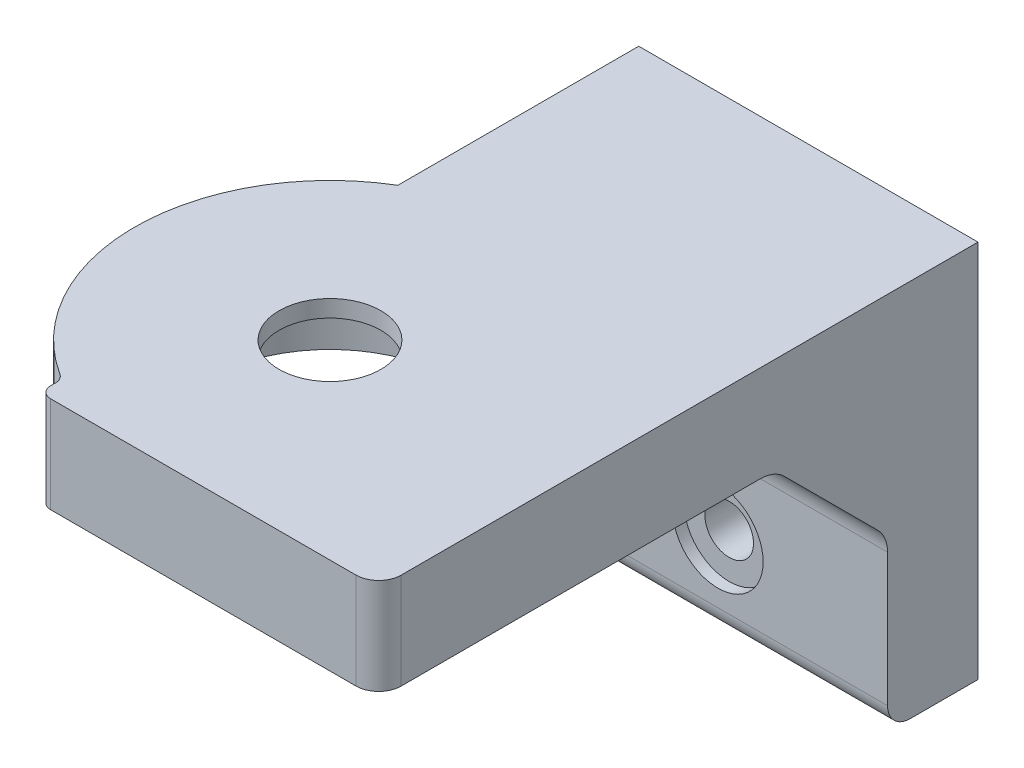
from build123d import *

# Parameters (mm, degrees)
CROQUIS3_R              = 11
CROQUIS3_R_2            = 4.5
SALIENTE_EXTRUIR2_DEPTH = 1.5
SALIENTE_EXTRUIR3_START = -1.5
CROQUIS3_3_R            = 11
SALIENTE_EXTRUIR3_DEPTH = 7
CROQUIS4_W              = 30
CROQUIS4_H              = 25
SALIENTE_EXTRUIR4_DEPTH = 8
CHAFL_N1_SIZE           = 10
CROQUIS5_R              = 2.15
CORTAR_EXTRUIR1_DEPTH   = 9
REDONDEO1_R             = 1
REDONDEO2_R             = 2
REDONDEO3_R             = 3
REDONDEO4_R             = 2
CROQUIS5_3_R            = 4
CROQUIS5_3_R_2          = 2.15
CORTAR_EXTRUIR2_DEPTH   = 1


with BuildPart() as part:
    # Croquis3 → Saliente-Extruir2 (new body)
    with BuildSketch(Plane(origin=(0, -625, 0), x_dir=(1, 0, 0), z_dir=(0, 1, 0))):
        with BuildLine():
            ThreePointArc((-40.300000436, -51), (-48.73713438, -36.15), (-40.300000436, -21.3))
            Line((-40.300000436, -21.3), (-40.300000436, 0))
            Line((-40.300000436, 0), (-10.300000436, 0))
            Line((-10.300000436, 0), (-10.300000436, -53))
            Line((-10.300000436, -53), (-40.300000436, -53))
            Line((-40.300000436, -53), (-40.300000436, -51))
        make_face()
        with Locations((-31.450000436, -36.15)):
            Circle(CROQUIS3_R, mode=Mode.SUBTRACT)
        with Locations((-31.450000436, -36.15)):
            Circle(CROQUIS3_R)
        with Locations((-31.450000436, -36.15)):
            Circle(CROQUIS3_R_2, mode=Mode.SUBTRACT)
    extrude(amount=-SALIENTE_EXTRUIR2_DEPTH)

    # Croquis3_3 → Saliente-Extruir3 (add)
    with BuildSketch(Plane(origin=(0, -625, 0), x_dir=(1, 0, 0), z_dir=(0, 1, 0)).offset(SALIENTE_EXTRUIR3_START)):
        with BuildLine():
            ThreePointArc((-40.300000436, -51), (-48.73713438, -36.15), (-40.300000436, -21.3))
            Line((-40.300000436, -21.3), (-40.300000436, 0))
            Line((-40.300000436, 0), (-10.300000436, 0))
            Line((-10.300000436, 0), (-10.300000436, -53))
            Line((-10.300000436, -53), (-40.300000436, -53))
            Line((-40.300000436, -53), (-40.300000436, -51))
        make_face()
        with Locations((-31.450000436, -36.15)):
            Circle(CROQUIS3_3_R, mode=Mode.SUBTRACT)
    extrude(amount=-SALIENTE_EXTRUIR3_DEPTH)

    # Croquis4 → Saliente-Extruir4 (add)
    with BuildSketch(Plane(origin=(0, 0, 0), x_dir=(-1, 0, 0), z_dir=(0, 0, -1))):
        with Locations((25.300000436, -646)):
            Rectangle(CROQUIS4_W, CROQUIS4_H)
    extrude(amount=-SALIENTE_EXTRUIR4_DEPTH)

    # Chaflán1
    chafl_n1_edges = [part.edges().sort_by_distance(p)[0] for p in [
        (-25.300000436, -633.5, 8),
    ]]
    chamfer(chafl_n1_edges, length=CHAFL_N1_SIZE)

    # Croquis5 → Cortar-Extruir1 (cut, through all)
    with BuildSketch(Plane.XY.offset(8)):
        with Locations((-25.300000436, -651)):
            Circle(CROQUIS5_R)
    extrude(amount=-CORTAR_EXTRUIR1_DEPTH, mode=Mode.SUBTRACT)

    # Redondeo1
    redondeo1_edges = [part.edges().sort_by_distance(p)[0] for p in [
        (-40.300000436, -629.25, 53),
        (-40.300000436, -629.25, 51),
    ]]
    fillet(redondeo1_edges, radius=REDONDEO1_R)

    # Redondeo2
    redondeo2_edges = [part.edges().sort_by_distance(p)[0] for p in [
        (-10.300000436, -629.25, 53),
    ]]
    fillet(redondeo2_edges, radius=REDONDEO2_R)

    # Redondeo3
    redondeo3_edges = [part.edges().sort_by_distance(p)[0] for p in [
        (-25.300000436, -633.5, 18),
        (-25.300000436, -643.5, 8),
    ]]
    fillet(redondeo3_edges, radius=REDONDEO3_R)

    # Redondeo4
    redondeo4_edges = [part.edges().sort_by_distance(p)[0] for p in [
        (-25.300000436, -658.5, 8),
    ]]
    fillet(redondeo4_edges, radius=REDONDEO4_R)

    # Croquis5_3 → Cortar-Extruir2 (cut)
    with BuildSketch(Plane.XY.offset(8)):
        with Locations((-25.300000436, -651)):
            Circle(CROQUIS5_3_R)
        with Locations((-25.300000436, -651)):
            Circle(CROQUIS5_3_R_2, mode=Mode.SUBTRACT)
    extrude(amount=-CORTAR_EXTRUIR2_DEPTH, mode=Mode.SUBTRACT)


solid = part.part
